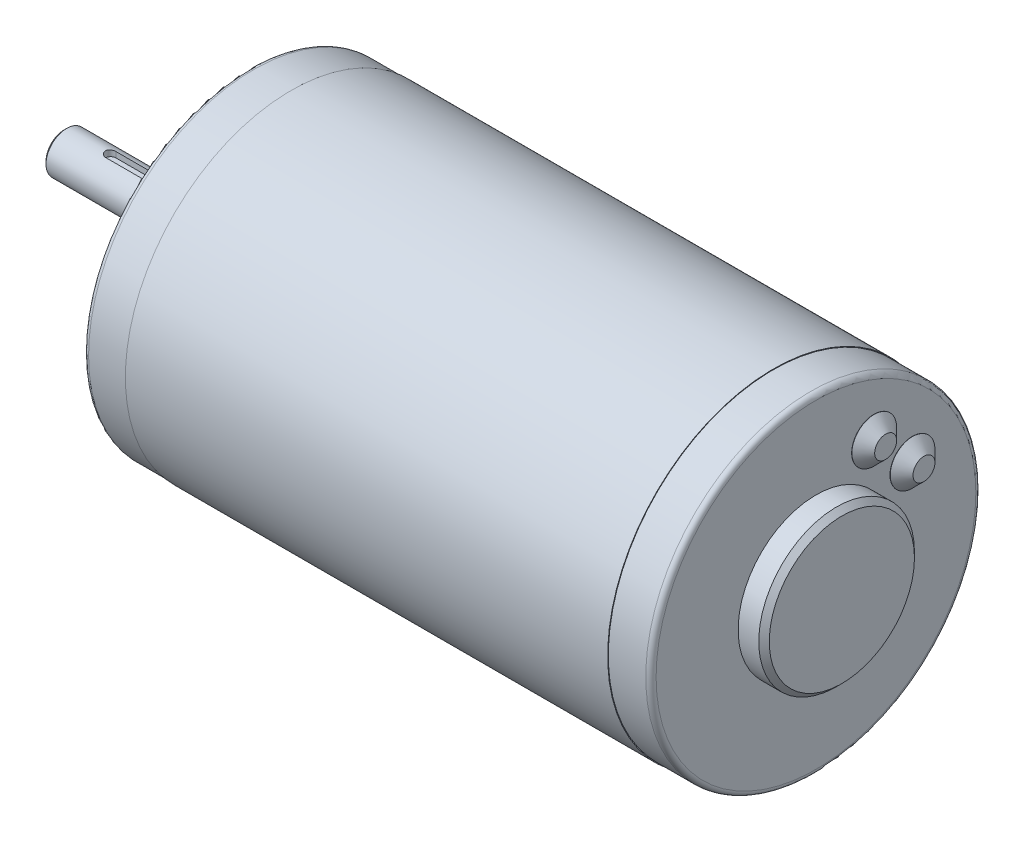
from build123d import *

# Parameters (mm, degrees)
SKETCH1_W                  = 93.1408
SKETCH1_H                  = 32.004
SKETCH2_R                  = 31.877
BOSS_EXTRUDE1_DEPTH        = 8.2296
SKETCH3_R                  = 15.0368
BOSS_EXTRUDE2_DEPTH        = 3.984
SKETCH4_R                  = 15.0368
BOSS_EXTRUDE3_DEPTH        = 1.016
BOSS_EXTRUDE3_TAPER        = 45
SKETCH5_R                  = 31.877
BOSS_EXTRUDE4_DEPTH        = 8.2296
SKETCH6_R                  = 9.525
BOSS_EXTRUDE5_DEPTH        = 4
SKETCH7_R                  = 4
BOSS_EXTRUDE6_DEPTH        = 31.6
M3_5_CLEARANCE_HOLE1_D     = 4.0386
M3_5_CLEARANCE_HOLE1_DEPTH = 13.6144
M3_5_CLEARANCE_HOLE1_TIP   = 1.213317848
CHAMFER1_SIZE              = 1.016
CHAMFER2_SIZE              = 0.5
FILLET1_R                  = 1
CUT_EXTRUDE2_DEPTH         = 2.54


with BuildPart() as part:
    # Sketch1 → Revolve1 (revolve)
    with BuildSketch(Plane.XY):
        with Locations((54.8, 16.002)):
            Rectangle(SKETCH1_W, SKETCH1_H)
    revolve(axis=Axis((8.2296, 0, 0), (1, 0, 0)))

    # Sketch2 → Boss-Extrude1 (add)
    with BuildSketch(Plane(origin=(101.3704, 0, 0), x_dir=(0, 0, -1), z_dir=(1, 0, 0))):
        Circle(SKETCH2_R)
    extrude(amount=BOSS_EXTRUDE1_DEPTH)

    # Sketch3 → Boss-Extrude2 (add)
    with BuildSketch(Plane(origin=(109.6, 0, 0), x_dir=(0, 0, -1), z_dir=(1, 0, 0))):
        Circle(SKETCH3_R)
    extrude(amount=BOSS_EXTRUDE2_DEPTH)

    # Sketch4 → Boss-Extrude3 (add)
    with BuildSketch(Plane(origin=(113.584, 0, 0), x_dir=(0, 0, -1), z_dir=(1, 0, 0))):
        Circle(SKETCH4_R)
    extrude(amount=BOSS_EXTRUDE3_DEPTH, taper=BOSS_EXTRUDE3_TAPER)

    # Sketch5 → Boss-Extrude4 (add)
    with BuildSketch(Plane.ZY.offset(-8.2296)):
        Circle(SKETCH5_R)
    extrude(amount=BOSS_EXTRUDE4_DEPTH)

    # Sketch6 → Boss-Extrude5 (add)
    with BuildSketch(Plane.ZY):
        Circle(SKETCH6_R)
    extrude(amount=BOSS_EXTRUDE5_DEPTH)

    # Sketch7 → Boss-Extrude6 (add)
    with BuildSketch(Plane.ZY.offset(4)):
        Circle(SKETCH7_R)
    extrude(amount=BOSS_EXTRUDE6_DEPTH)

    # Sketch9 → Revolve2 (revolve)
    with BuildSketch(Plane.XY.offset(-18.607090683)):
        Polygon((109.6, 15.525359639), (109.6, 11.207359639), (111.8479, 11.207359639), (111.8479, 13.325359639), (109.6479, 15.525359639), align=None)
    revolve(axis=Axis((109.6, 11.207359639, -18.607090683), (1, 0, 0)))

    # Sketch10 → Revolve3 (revolve)
    with BuildSketch(Plane.XY.offset(-11.207359639)):
        Polygon((109.6, 22.925090683), (109.6, 18.607090683), (111.8479, 18.607090683), (111.8479, 20.725090683), (109.6479, 22.925090683), align=None)
    revolve(axis=Axis((109.6, 18.607090683, -11.207359639), (1, 0, 0)))

    # M3.5 Clearance Hole1
    with Locations(Plane.ZY):
        with Locations((0, 25.4), (0, -25.4)):
            Hole(M3_5_CLEARANCE_HOLE1_D / 2, depth=M3_5_CLEARANCE_HOLE1_DEPTH)
            with Locations((0, 0, -(M3_5_CLEARANCE_HOLE1_DEPTH + M3_5_CLEARANCE_HOLE1_TIP / 2))):  # 118° drill point
                Cone(0, M3_5_CLEARANCE_HOLE1_D / 2, M3_5_CLEARANCE_HOLE1_TIP, mode=Mode.SUBTRACT)

    # Chamfer1
    chamfer1_edges = [part.edges().sort_by_distance(p)[0] for p in [
        (-4, 0, -9.525),
    ]]
    chamfer(chamfer1_edges, length=CHAMFER1_SIZE)

    # Chamfer2
    chamfer2_edges = [part.edges().sort_by_distance(p)[0] for p in [
        (-35.6, 0, -4),
    ]]
    chamfer(chamfer2_edges, length=CHAMFER2_SIZE)

    # Fillet1
    fillet1_edges = [part.edges().sort_by_distance(p)[0] for p in [
        (0, 0, -31.877),
        (109.6, 0, 31.877),
    ]]
    fillet(fillet1_edges, radius=FILLET1_R)

    # Sketch8 → Cut-Extrude2 (cut)
    with BuildSketch(Plane.XZ.offset(-2.8)):
        with BuildLine():
            Line((-7.1, 1), (-26.6, 1))
            ThreePointArc((-26.6, 1), (-27.6, 0), (-26.6, -1))
            Line((-26.6, -1), (-7.1, -1))
            ThreePointArc((-7.1, -1), (-6.1, 0), (-7.1, 1))
        make_face()
    extrude(amount=-CUT_EXTRUDE2_DEPTH, mode=Mode.SUBTRACT)


solid = part.part
